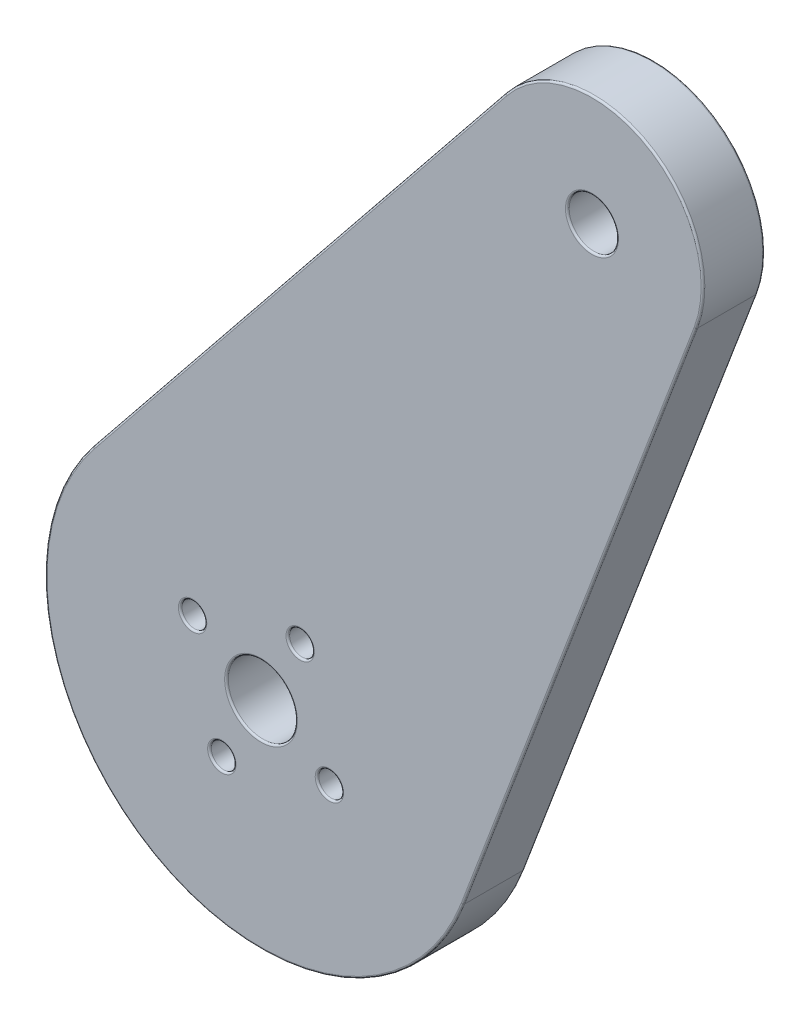
from build123d import *

# Parameters (mm, degrees)
SKETCH1_R           = 2.8
SKETCH1_R_2         = 2
SKETCH1_R_3         = 1
BOSS_EXTRUDE1_DEPTH = 5
FILLET1_R           = 0.15


with BuildPart() as part:
    # Sketch1 → Boss-Extrude1 (new body)
    with BuildSketch(Plane.XY):
        with BuildLine():
            Line((-33.848494558, 68.557893062), (-0.396142845, 110.087282233))
            ThreePointArc((-0.396142845, 110.087282233), (11.084930082, 112.251760101), (15.029630952, 101.254517945))
            Line((15.029630952, 101.254517945), (-3.853934396, 51.383073613))
            ThreePointArc((-3.853934396, 51.383073613), (-28.915813912, 42.393399972), (-33.848494558, 68.557893062))
        make_face()
        with Locations((-20.22, 57.58)):
            Circle(SKETCH1_R, mode=Mode.SUBTRACT)
        with Locations((6.612797213, 104.441508658)):
            Circle(SKETCH1_R_2, mode=Mode.SUBTRACT)
        with Locations((-25.765278525, 60.755214337)):
            Circle(SKETCH1_R_3, mode=Mode.SUBTRACT)
        with Locations((-17.044785663, 63.125278525)):
            Circle(SKETCH1_R_3, mode=Mode.SUBTRACT)
        with Locations((-23.395214337, 52.034721475)):
            Circle(SKETCH1_R_3, mode=Mode.SUBTRACT)
        with Locations((-14.674721475, 54.404785663)):
            Circle(SKETCH1_R_3, mode=Mode.SUBTRACT)
    extrude(amount=-BOSS_EXTRUDE1_DEPTH)

    # Fillet1
    fillet1_edges = [part.edges().sort_by_distance(p)[0] for p in [
        (-23.02, 57.58, -5),
        (-23.02, 57.58, 0),
        (11.084930082, 112.251760101, -5),
        (4.612797213, 104.441508658, -5),
        (4.612797213, 104.441508658, 0),
        (-17.122318702, 89.322587648, -5),
        (-26.765278525, 60.755214337, -5),
        (-26.765278525, 60.755214337, 0),
        (-18.044785663, 63.125278525, -5),
        (-18.044785663, 63.125278525, 0),
        (-24.395214337, 52.034721475, -5),
        (-24.395214337, 52.034721475, 0),
        (-15.674721475, 54.404785663, -5),
        (-15.674721475, 54.404785663, 0),
        (-28.915813912, 42.393399972, -5),
        (-17.122318702, 89.322587648, 0),
        (11.084930082, 112.251760101, 0),
        (5.587848278, 76.318795779, 0),
        (-28.915813912, 42.393399972, 0),
        (5.587848278, 76.318795779, -5),
    ]]
    fillet(fillet1_edges, radius=FILLET1_R)


solid = part.part
